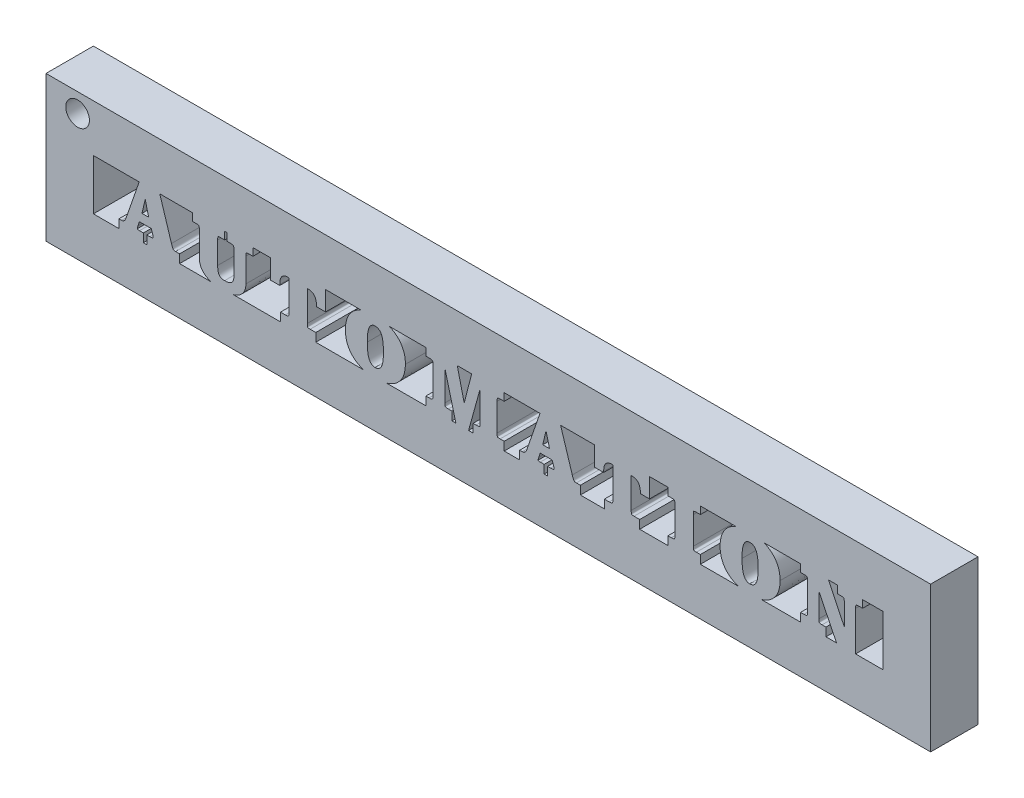
from build123d import *

# Parameters (mm, degrees)
BOSS_EXTRUDE1_DEPTH    = 3
BOSS_EXTRUDE1_2_DEPTH  = 3
BOSS_EXTRUDE1_3_DEPTH  = 3
BOSS_EXTRUDE1_4_DEPTH  = 3
BOSS_EXTRUDE1_5_DEPTH  = 3
BOSS_EXTRUDE1_6_DEPTH  = 3
BOSS_EXTRUDE1_7_DEPTH  = 3
BOSS_EXTRUDE1_8_DEPTH  = 3
BOSS_EXTRUDE1_9_DEPTH  = 3
BOSS_EXTRUDE1_10_DEPTH = 3
SKETCH3_W              = 56
SKETCH3_H              = 9.2
SKETCH3_W_2            = 50
SKETCH3_H_2            = 3.2
BOSS_EXTRUDE2_DEPTH    = 3
SKETCH4_R              = 0.75
CUT_EXTRUDE1_DEPTH     = 3


with BuildPart() as part:
    # Sketch2 → Boss-Extrude1 (new body)
    with BuildSketch(Plane.XY):
        with BuildLine():
            Line((3.381832038, 0), (3.381832038, 0.536056858))
            Line((3.381832038, 0.536056858), (3.570987518, 0.536056858))
            add(Edge.make_bspline(
                [(3.570987518, 0.536056858), (3.596342853, 0.536171578), (3.641017257, 0.536373708), (3.698829642, 0.53805499), (3.738173785, 0.541308891), (3.766455813, 0.545460082), (3.786381886, 0.562207471), (3.787958851, 0.579113011), (3.788760616, 0.587708169)],
                knots=[0, 0, 0, 0, 7.6084e-05, 0.000134055, 0.000173298, 0.0001948, 0.00021903, 0.00024409, 0.00024409, 0.00024409, 0.00024409], degree=3))
            add(Edge.make_bspline(
                [(3.788760616, 0.587708169), (3.788482764, 0.597959418), (3.787912273, 0.619007516), (3.783446166, 0.650694941), (3.77732226, 0.681848648), (3.772315457, 0.702195094), (3.769914867, 0.711950514)],
                knots=[0, 0, 0, 0, 3.0743e-05, 6.3123e-05, 9.5839e-05, 0.000125974, 0.000125974, 0.000125974, 0.000125974], degree=3))
            Line((3.769914867, 0.711950514), (3.665914253, 1.02744231))
            Line((3.665914253, 1.02744231), (2.912084297, 1.02744231))
            Line((2.912084297, 1.02744231), (2.821345506, 0.749642012))
            add(Edge.make_bspline(
                [(2.821345506, 0.749642012), (2.814741406, 0.729429284), (2.803333299, 0.694513256), (2.789391024, 0.648275702), (2.782829669, 0.611879239), (2.782916307, 0.590518691), (2.782956017, 0.580728262)],
                knots=[0, 0, 0, 0, 6.3793e-05, 0.000110197, 0.000144852, 0.000174176, 0.000174176, 0.000174176, 0.000174176], degree=3))
            add(Edge.make_bspline(
                [(2.782956017, 0.580728262), (2.784157263, 0.573240487), (2.786647185, 0.557719942), (2.805768298, 0.545459648), (2.826429588, 0.540840547), (2.850174249, 0.538549009), (2.881090993, 0.536254741), (2.904164107, 0.536127487), (2.916970232, 0.536056858)],
                knots=[0, 0, 0, 0, 2.1862e-05, 4.5315e-05, 6.1906e-05, 8.5801e-05, 0.000116584, 0.00015498, 0.00015498, 0.00015498, 0.00015498], degree=3))
            Line((2.916970232, 0.536056858), (3.16475693, 0.536056858))
            Line((3.16475693, 0.536056858), (3.16475693, 0))
            Line((3.16475693, 0), (1.614519586, 0))
            Line((1.614519586, 0), (1.614519586, 0.536056858))
            Line((1.614519586, 0.536056858), (1.777151419, 0.536056858))
            add(Edge.make_bspline(
                [(1.777151419, 0.536056858), (1.793748064, 0.536834102), (1.826279255, 0.538357585), (1.872910412, 0.551114453), (1.915175634, 0.572783209), (1.954099296, 0.603015499), (1.989492009, 0.644535735), (2.022918471, 0.697314513), (2.053043362, 0.762945126), (2.070671551, 0.811159662), (2.080079382, 0.836890849)],
                knots=[0, 0, 0, 0, 4.9734e-05, 9.7484e-05, 0.000143683, 0.000191433, 0.000244356, 0.000306509, 0.000378321, 0.000460506, 0.000460506, 0.000460506, 0.000460506], degree=3))
            Line((2.080079382, 0.836890849), (2.919762195, 3.261012551))
            Line((2.919762195, 3.261012551), (4.183823352, 3.261012551))
            Line((4.183823352, 3.261012551), (4.941841253, 0.845266738))
            add(Edge.make_bspline(
                [(4.941841253, 0.845266738), (4.948028917, 0.826155434), (4.959679339, 0.790171785), (4.977625901, 0.739629309), (4.992775532, 0.69487605), (5.009294359, 0.657628397), (5.023108468, 0.626144229), (5.036090496, 0.601384535), (5.047744758, 0.582505931), (5.062855526, 0.566034588), (5.086036632, 0.553350471), (5.117765077, 0.5431571), (5.156363257, 0.536965551), (5.184253211, 0.53637667), (5.199399821, 0.536056858)],
                knots=[0, 0, 0, 0, 6.0258e-05, 0.000113457, 0.000160925, 0.000201893, 0.000235629, 0.000264041, 0.000285724, 0.000302019, 0.000330508, 0.000363617, 0.000401828, 0.000447246, 0.000447246, 0.000447246, 0.000447246], degree=3))
            Line((5.199399821, 0.536056858), (5.456260399, 0.536056858))
            Line((5.456260399, 0.536056858), (5.456260399, 0))
            Line((5.456260399, 0), (3.381832038, 0))
        make_face()
        Polygon((3.502584429, 1.563499168), (3.279925396, 2.434591562), (3.074018139, 1.563499168), align=None, mode=Mode.SUBTRACT)
    extrude(amount=BOSS_EXTRUDE1_DEPTH)



with BuildPart() as body_2:
    # Sketch2 → Boss-Extrude1 2 (new body)
    with BuildSketch(Plane.XY):
        with BuildLine():
            add(Edge.make_bspline(
                [(7.868516258, 1.10701325), (7.868707123, 1.077923127), (7.869072362, 1.022256245), (7.873932025, 0.942342272), (7.882204374, 0.869888516), (7.893278232, 0.804852562), (7.906709904, 0.7469007), (7.924849947, 0.696675514), (7.945830395, 0.653570995), (7.969517199, 0.616709057), (7.998666652, 0.587190467), (8.030082332, 0.560826844), (8.066150595, 0.539101064), (8.106422363, 0.521805027), (8.150550321, 0.507704864), (8.198785943, 0.498175384), (8.250886173, 0.492655301), (8.286831413, 0.491818887), (8.305458436, 0.491385453)],
                knots=[0, 0, 0, 0, 8.726e-05, 0.000166981, 0.000240053, 0.00030592, 0.000364833, 0.000418265, 0.000465713, 0.000508496, 0.000548979, 0.000589643, 0.000631301, 0.000674745, 0.000720881, 0.000770023, 0.000821976, 0.000877854, 0.000877854, 0.000877854, 0.000877854], degree=3))
            add(Edge.make_bspline(
                [(8.305458436, 0.491385453), (8.331303094, 0.491722183), (8.380980465, 0.492369429), (8.452473231, 0.499092046), (8.518487406, 0.508064313), (8.578500462, 0.523234703), (8.633484757, 0.540558083), (8.681798096, 0.564178469), (8.725003671, 0.590312162), (8.762000991, 0.621800119), (8.794233967, 0.658067778), (8.820898537, 0.700462835), (8.84537275, 0.747484067), (8.863643675, 0.80100877), (8.878312449, 0.85985571), (8.888541078, 0.92431251), (8.894874761, 0.994276445), (8.895588581, 1.042783561), (8.895958568, 1.067925771)],
                knots=[0, 0, 0, 0, 7.7505e-05, 0.000148977, 0.000215312, 0.000277103, 0.000334491, 0.000387877, 0.00043804, 0.000485585, 0.000533059, 0.000583008, 0.00063545, 0.000691746, 0.000752182, 0.000817245, 0.000887326, 0.000962738, 0.000962738, 0.000962738, 0.000962738], degree=3))
            Line((8.895958568, 1.067925771), (8.895958568, 2.500202688))
            add(Edge.make_bspline(
                [(8.895958568, 2.500202688), (8.895768763, 2.524886933), (8.895431099, 2.568800309), (8.888621896, 2.626444708), (8.87934257, 2.667875118), (8.862185167, 2.697373844), (8.830958932, 2.71101168), (8.789394628, 2.718684183), (8.732490529, 2.723987746), (8.689589849, 2.724608746), (8.665621637, 2.724955693)],
                knots=[0, 0, 0, 0, 7.4017e-05, 0.000131676, 0.000173672, 0.000201355, 0.000229767, 0.000271936, 0.000328749, 0.000400672, 0.000400672, 0.000400672, 0.000400672], degree=3))
            Line((8.665621637, 2.724955693), (8.44924452, 2.724955693))
            Line((8.44924452, 2.724955693), (8.44924452, 3.261012551))
            Line((8.44924452, 3.261012551), (10.102086498, 3.261012551))
            Line((10.102086498, 3.261012551), (10.102086498, 2.724955693))
            Line((10.102086498, 2.724955693), (9.852903818, 2.724955693))
            add(Edge.make_bspline(
                [(9.852903818, 2.724955693), (9.83197497, 2.724824859), (9.794690979, 2.724591782), (9.745368172, 2.720083001), (9.710238708, 2.712923942), (9.682722037, 2.702892056), (9.668710345, 2.675488816), (9.66165712, 2.636803368), (9.656236887, 2.581033839), (9.655685291, 2.538363339), (9.65537245, 2.514162502)],
                knots=[0, 0, 0, 0, 6.2835e-05, 0.000111938, 0.000147672, 0.000171709, 0.000195533, 0.000234981, 0.000290404, 0.000363025, 0.000363025, 0.000363025, 0.000363025], degree=3))
            Line((9.65537245, 2.514162502), (9.65537245, 0.989750813))
            add(Edge.make_bspline(
                [(9.65537245, 0.989750813), (9.654175093, 0.947803989), (9.651841742, 0.866060123), (9.633399012, 0.747046894), (9.602876321, 0.635393575), (9.559408101, 0.531107207), (9.50281535, 0.434775672), (9.43459066, 0.345263785), (9.353728717, 0.263454323), (9.261063587, 0.189097827), (9.156378237, 0.123577708), (9.040370538, 0.066225613), (8.913318827, 0.017439247), (8.774610058, -0.02131287), (8.62505696, -0.051746424), (8.463986775, -0.073943293), (8.291724772, -0.087241597), (8.173097138, -0.088629394), (8.112115012, -0.08934281)],
                knots=[0, 0, 0, 0, 0.000125795, 0.000245144, 0.000360295, 0.000472296, 0.00058303, 0.000694574, 0.000809082, 0.000927247, 0.001050214, 0.001178821, 0.001314927, 0.001457879, 0.001610374, 0.001772458, 0.001945371, 0.002128292, 0.002128292, 0.002128292, 0.002128292], degree=3))
            add(Edge.make_bspline(
                [(8.112115012, -0.08934281), (8.058348019, -0.088558927), (7.953684375, -0.08703301), (7.801139761, -0.074638252), (7.657867159, -0.052738044), (7.523199971, -0.024141065), (7.39823319, 0.014484406), (7.281852305, 0.060439148), (7.174904107, 0.115495291), (7.077566607, 0.179078755), (6.990269738, 0.250288656), (6.914854002, 0.329676728), (6.849351673, 0.415095977), (6.797797101, 0.509106111), (6.757021701, 0.609607696), (6.727734585, 0.717106499), (6.709908252, 0.831640403), (6.708024614, 0.910346597), (6.707059733, 0.950663333)],
                knots=[0, 0, 0, 0, 0.00016129, 0.00031397, 0.000458685, 0.000595868, 0.000726573, 0.000850613, 0.000970802, 0.001086765, 0.001198835, 0.001307939, 0.001414592, 0.001520826, 0.001628537, 0.00173928, 0.001854383, 0.001975264, 0.001975264, 0.001975264, 0.001975264], degree=3))
            Line((6.707059733, 0.950663333), (6.707059733, 2.500202688))
            add(Edge.make_bspline(
                [(6.707059733, 2.500202688), (6.706814492, 2.52417641), (6.706377371, 2.566907454), (6.700086066, 2.623358829), (6.689284834, 2.664306778), (6.672002427, 2.694433509), (6.640294362, 2.709932178), (6.597913611, 2.717876999), (6.540866583, 2.724270361), (6.497914307, 2.724710134), (6.473930839, 2.724955693)],
                knots=[0, 0, 0, 0, 7.1924e-05, 0.000128197, 0.000169715, 0.000198947, 0.000228642, 0.000271647, 0.000328532, 0.000400455, 0.000400455, 0.000400455, 0.000400455], degree=3))
            Line((6.473930839, 2.724955693), (6.260345685, 2.724955693))
            Line((6.260345685, 2.724955693), (6.260345685, 3.261012551))
            Line((6.260345685, 3.261012551), (8.315230306, 3.261012551))
            Line((8.315230306, 3.261012551), (8.315230306, 2.724955693))
            Line((8.315230306, 2.724955693), (8.047899868, 2.724955693))
            add(Edge.make_bspline(
                [(8.047899868, 2.724955693), (8.029048445, 2.724842914), (7.995217807, 2.724640523), (7.950455591, 2.719858127), (7.917814983, 2.713337696), (7.892497853, 2.701349448), (7.879886533, 2.672944288), (7.874601773, 2.631738955), (7.868338274, 2.572216321), (7.868451821, 2.526274171), (7.868516258, 2.500202688)],
                knots=[0, 0, 0, 0, 5.6554e-05, 0.000101492, 0.000134505, 0.000157015, 0.000181692, 0.000222897, 0.000282489, 0.000360676, 0.000360676, 0.000360676, 0.000360676], degree=3))
            Line((7.868516258, 2.500202688), (7.868516258, 1.10701325))
        make_face()
    extrude(amount=BOSS_EXTRUDE1_2_DEPTH)


with BuildPart() as body_3:
    # Sketch2 → Boss-Extrude1 3 (new body)
    with BuildSketch(Plane.XY):
        with BuildLine():
            add(Edge.make_bspline(
                [(12.279119492, 2.680284288), (12.261188832, 2.679636513), (12.226123323, 2.678369713), (12.174737753, 2.671723374), (12.126699318, 2.658843822), (12.081036093, 2.642148757), (12.038503664, 2.619606552), (11.998708109, 2.592419951), (11.961763568, 2.560300878), (11.927604834, 2.523659756), (11.897408311, 2.481052415), (11.870754161, 2.43341156), (11.848511744, 2.379968596), (11.830471135, 2.321041416), (11.816582842, 2.256582581), (11.807235729, 2.186551757), (11.800636235, 2.111080948), (11.799953109, 2.058855491), (11.799599881, 2.031850928)],
                knots=[0, 0, 0, 0, 5.3818e-05, 0.000105247, 0.00015502, 0.000202729, 0.00025081, 0.000299016, 0.000347016, 0.000397397, 0.000448921, 0.000503292, 0.00056085, 0.000622226, 0.000687941, 0.00075842, 0.000834065, 0.000915059, 0.000915059, 0.000915059, 0.000915059], degree=3))
            Line((11.799599881, 2.031850928), (11.799599881, 1.9739177))
            Line((11.799599881, 1.9739177), (11.218871618, 1.9739177))
            Line((11.218871618, 1.9739177), (11.218871618, 3.261012551))
            Line((11.218871618, 3.261012551), (14.703241193, 3.261012551))
            Line((14.703241193, 3.261012551), (14.703241193, 1.9739177))
            Line((14.703241193, 1.9739177), (14.12251293, 1.9739177))
            Line((14.12251293, 1.9739177), (14.12251293, 2.031850928))
            add(Edge.make_bspline(
                [(14.12251293, 2.031850928), (14.122109942, 2.05768537), (14.121328107, 2.107806652), (14.115338178, 2.180656207), (14.103747074, 2.248365992), (14.089814371, 2.311706246), (14.069595289, 2.369734423), (14.047347907, 2.423862222), (14.018964656, 2.472347558), (13.986755068, 2.515752782), (13.950967077, 2.554675432), (13.910837575, 2.588404091), (13.866957755, 2.616911762), (13.819203251, 2.640445536), (13.767851178, 2.658362023), (13.712577821, 2.670863551), (13.653684814, 2.678661352), (13.613004958, 2.679732339), (13.592039998, 2.680284288)],
                knots=[0, 0, 0, 0, 7.7505e-05, 0.000150368, 0.000218988, 0.000283494, 0.000344635, 0.000403108, 0.000458777, 0.000512663, 0.000565017, 0.00061703, 0.000669495, 0.000721625, 0.000776372, 0.000832246, 0.000891378, 0.000954259, 0.000954259, 0.000954259, 0.000954259], degree=3))
            Line((13.592039998, 2.680284288), (13.541784668, 2.680284288))
            Line((13.541784668, 2.680284288), (13.541784668, 0.764997807))
            add(Edge.make_bspline(
                [(13.541784668, 0.764997807), (13.541765258, 0.738478477), (13.541731145, 0.691870055), (13.547550118, 0.630977659), (13.55401725, 0.589225928), (13.566237487, 0.559444145), (13.592204092, 0.548029508), (13.624346101, 0.54101405), (13.668509319, 0.536415579), (13.701860283, 0.536185335), (13.720470287, 0.536056858)],
                knots=[0, 0, 0, 0, 7.9583e-05, 0.00013987, 0.000182578, 0.00020787, 0.000230988, 0.000263323, 0.000307567, 0.000363424, 0.000363424, 0.000363424, 0.000363424], degree=3))
            Line((13.720470287, 0.536056858), (14.077841526, 0.536056858))
            Line((14.077841526, 0.536056858), (14.077841526, 0))
            Line((14.077841526, 0), (11.844271285, 0))
            Line((11.844271285, 0), (11.844271285, 0.536056858))
            Line((11.844271285, 0.536056858), (12.149991212, 0.536056858))
            add(Edge.make_bspline(
                [(12.149991212, 0.536056858), (12.173261577, 0.536087275), (12.215005856, 0.536141841), (12.270706264, 0.541822249), (12.311677494, 0.549129584), (12.343908431, 0.560765498), (12.362705215, 0.590208826), (12.372353433, 0.63291486), (12.380106865, 0.692854114), (12.380248114, 0.738905894), (12.380328143, 0.764997807)],
                knots=[0, 0, 0, 0, 6.9813e-05, 0.000125236, 0.000167261, 0.000195682, 0.000224163, 0.00026702, 0.000326844, 0.000405047, 0.000405047, 0.000405047, 0.000405047], degree=3))
            Line((12.380328143, 0.764997807), (12.380328143, 2.680284288))
            Line((12.380328143, 2.680284288), (12.279119492, 2.680284288))
        make_face()
    extrude(amount=BOSS_EXTRUDE1_3_DEPTH)


with BuildPart() as body_4:
    # Sketch2 → Boss-Extrude1 4 (new body)
    with BuildSketch(Plane.XY):
        with BuildLine():
            add(Edge.make_bspline(
                [(15.954040527, 1.628412303), (15.955360908, 1.693871405), (15.957935735, 1.821520791), (15.982420667, 2.007230092), (16.02086911, 2.182340646), (16.076650373, 2.34627067), (16.145988685, 2.500575332), (16.233399644, 2.642867483), (16.33610488, 2.774304619), (16.453544173, 2.894467164), (16.584777963, 3.002061051), (16.728852005, 3.095042276), (16.88426974, 3.174540771), (17.051558104, 3.239241172), (17.23059163, 3.289630125), (17.4212787, 3.324537203), (17.623569439, 3.346831303), (17.762473223, 3.349160504), (17.833729483, 3.35035536)],
                knots=[0, 0, 0, 0, 0.000196286, 0.000382769, 0.00056091, 0.000733297, 0.000901339, 0.001067374, 0.001232969, 0.001400789, 0.001570416, 0.00174098, 0.001914231, 0.002093235, 0.002278182, 0.002471344, 0.00267422, 0.002887919, 0.002887919, 0.002887919, 0.002887919], degree=3))
            add(Edge.make_bspline(
                [(17.833729483, 3.35035536), (17.906850767, 3.349221369), (18.049499578, 3.347009121), (18.257120018, 3.323849865), (18.452680847, 3.288293271), (18.635735264, 3.237385548), (18.80649817, 3.17165401), (18.964827217, 3.091168279), (19.111528855, 2.996520673), (19.244354727, 2.886735701), (19.364169864, 2.765490921), (19.46795862, 2.632813836), (19.555853872, 2.490271065), (19.627329958, 2.337474619), (19.683476559, 2.174681532), (19.722798252, 2.001507145), (19.74715365, 1.818263654), (19.749770133, 1.692705801), (19.751109936, 1.628412303)],
                knots=[0, 0, 0, 0, 0.00021928, 0.000427783, 0.000625876, 0.000815043, 0.000996903, 0.001173897, 0.001346978, 0.001519552, 0.001689835, 0.001857389, 0.002023789, 0.002191151, 0.002362442, 0.002539377, 0.002723092, 0.00291589, 0.00291589, 0.00291589, 0.00291589], degree=3))
            add(Edge.make_bspline(
                [(19.751109936, 1.628412303), (19.74982705, 1.564113301), (19.747316508, 1.438283469), (19.722117912, 1.255085513), (19.682463731, 1.082100979), (19.627532121, 0.918854457), (19.55511083, 0.766220375), (19.467515305, 0.623361067), (19.363377355, 0.491384274), (19.24388928, 0.370692375), (19.110250138, 0.262333814), (18.963614508, 0.167624398), (18.804163232, 0.08780829), (18.632078817, 0.023077635), (18.44800686, -0.027873049), (18.251353239, -0.063822887), (18.042232405, -0.085760031), (17.898465443, -0.088127403), (17.824655603, -0.08934281)],
                knots=[0, 0, 0, 0, 0.000192798, 0.000377296, 0.000553551, 0.000724616, 0.000892907, 0.001059307, 0.001226312, 0.001396098, 0.001567789, 0.001741456, 0.001918758, 0.002101671, 0.002292183, 0.002490962, 0.00270078, 0.002922153, 0.002922153, 0.002922153, 0.002922153], degree=3))
            add(Edge.make_bspline(
                [(17.824655603, -0.08934281), (17.753863411, -0.088152744), (17.615885397, -0.085833238), (17.41476986, -0.063456884), (17.224989043, -0.028653218), (17.046987691, 0.021791519), (16.880302739, 0.085958279), (16.725494244, 0.165116317), (16.581940534, 0.258246674), (16.451432124, 0.366093247), (16.333985429, 0.48578982), (16.231940759, 0.617471422), (16.145620817, 0.759800337), (16.075706703, 0.913155321), (16.020989193, 1.076935386), (15.982440012, 1.251445896), (15.957967733, 1.436469133), (15.955370291, 1.563419766), (15.954040527, 1.628412303)],
                knots=[0, 0, 0, 0, 0.000212304, 0.000413792, 0.000606268, 0.000790543, 0.000967994, 0.001141244, 0.001311223, 0.001480312, 0.001648131, 0.001813297, 0.00197897, 0.002146377, 0.00231788, 0.002496021, 0.002681812, 0.002876703, 0.002876703, 0.002876703, 0.002876703], degree=3))
        make_face()
        with BuildLine():
            add(Edge.make_bspline(
                [(17.832333501, 2.769627098), (17.813201703, 2.768771897), (17.77549381, 2.767086336), (17.720644286, 2.755272428), (17.669572131, 2.734337274), (17.621519099, 2.706317637), (17.57713646, 2.669402601), (17.5367835, 2.623996383), (17.498873249, 2.571638984), (17.465156293, 2.510415797), (17.434908336, 2.439935077), (17.409551054, 2.358180351), (17.387440313, 2.26561374), (17.369465261, 2.16163292), (17.355747999, 2.046530871), (17.346441968, 1.920059115), (17.33987621, 1.782503939), (17.339203434, 1.6870521), (17.338854076, 1.637486182)],
                knots=[0, 0, 0, 0, 5.7388e-05, 0.00011311, 0.000167288, 0.000222354, 0.000279372, 0.000339658, 0.000404165, 0.000472909, 0.000548888, 0.000633874, 0.000729356, 0.00083424, 0.000950252, 0.001076965, 0.001214613, 0.0013633, 0.0013633, 0.0013633, 0.0013633], degree=3))
            add(Edge.make_bspline(
                [(17.338854076, 1.637486182), (17.33931872, 1.58699535), (17.340214049, 1.489703957), (17.345251336, 1.349507706), (17.355913502, 1.221022831), (17.369694323, 1.104117508), (17.386647005, 0.99867508), (17.40802561, 0.90484333), (17.433561791, 0.822502784), (17.463739001, 0.751298562), (17.497391339, 0.68973311), (17.534468059, 0.637111288), (17.574557463, 0.592012324), (17.618848482, 0.555755347), (17.665976781, 0.526337438), (17.716998921, 0.5059455), (17.771507454, 0.493831607), (17.809005074, 0.492212115), (17.828145557, 0.491385453)],
                knots=[0, 0, 0, 0, 0.000151478, 0.000291886, 0.000420742, 0.000538139, 0.000644971, 0.000740972, 0.000826623, 0.000903243, 0.000972598, 0.001036699, 0.001095999, 0.001153017, 0.001207844, 0.001262022, 0.001317062, 0.00137445, 0.00137445, 0.00137445, 0.00137445], degree=3))
            add(Edge.make_bspline(
                [(17.828145557, 0.491385453), (17.850524295, 0.492236693), (17.894212513, 0.493898501), (17.957710725, 0.505496917), (18.016250415, 0.527037919), (18.070460535, 0.555674981), (18.120040225, 0.592463144), (18.164382459, 0.637777298), (18.203528975, 0.691649366), (18.238697319, 0.753891209), (18.269508466, 0.825671097), (18.294696292, 0.908009918), (18.317034682, 1.000778373), (18.335720016, 1.104213428), (18.349414728, 1.218901686), (18.358687483, 1.344210164), (18.365268062, 1.480369437), (18.365945358, 1.574658426), (18.366296387, 1.623526368)],
                knots=[0, 0, 0, 0, 6.7138e-05, 0.000131068, 0.000192669, 0.000253559, 0.000314424, 0.000377107, 0.000443, 0.000513646, 0.000591182, 0.000676833, 0.000771637, 0.000877331, 0.000991957, 0.001117975, 0.001254228, 0.001400821, 0.001400821, 0.001400821, 0.001400821], degree=3))
            add(Edge.make_bspline(
                [(18.366296387, 1.623526368), (18.365955974, 1.672860661), (18.365300539, 1.767849392), (18.358608273, 1.904925509), (18.349634769, 2.031464901), (18.334772963, 2.146918514), (18.317034217, 2.251647222), (18.294840722, 2.345433045), (18.268816217, 2.428753976), (18.237802287, 2.501627693), (18.203097517, 2.565085668), (18.163461619, 2.619531393), (18.120120262, 2.666320661), (18.071600634, 2.704716665), (18.017633275, 2.733273922), (17.959953188, 2.754504241), (17.897579744, 2.767417644), (17.854498846, 2.768876506), (17.832333501, 2.769627098)],
                knots=[0, 0, 0, 0, 0.000147989, 0.000284939, 0.000411653, 0.000528443, 0.000634015, 0.000730176, 0.000817369, 0.000895547, 0.000967409, 0.001033865, 0.001097071, 0.001158228, 0.001218502, 0.001279447, 0.001342142, 0.001408584, 0.001408584, 0.001408584, 0.001408584], degree=3))
        make_face(mode=Mode.SUBTRACT)
    extrude(amount=BOSS_EXTRUDE1_4_DEPTH)


with BuildPart() as body_5:
    # Sketch2 → Boss-Extrude1 5 (new body)
    with BuildSketch(Plane.XY):
        with BuildLine():
            Line((26.005106608, 3.261012551), (26.005106608, 2.724955693))
            Line((26.005106608, 2.724955693), (25.746850049, 2.724955693))
            add(Edge.make_bspline(
                [(25.746850049, 2.724955693), (25.726854722, 2.724771649), (25.691455029, 2.724445819), (25.644259348, 2.720499589), (25.610759162, 2.714416491), (25.583711592, 2.704667841), (25.571285474, 2.675978268), (25.563437978, 2.634892014), (25.559713022, 2.573226067), (25.558870856, 2.525762795), (25.55839256, 2.498806706)],
                knots=[0, 0, 0, 0, 6.0043e-05, 0.000106301, 0.000141207, 0.000163684, 0.000187752, 0.00022924, 0.000290857, 0.000371851, 0.000371851, 0.000371851, 0.000371851], degree=3))
            Line((25.55839256, 2.498806706), (25.55839256, 0.764299817))
            add(Edge.make_bspline(
                [(25.55839256, 0.764299817), (25.558879602, 0.737118933), (25.559738152, 0.689204955), (25.563390473, 0.626769039), (25.571439238, 0.585191845), (25.58352759, 0.555460865), (25.611063421, 0.546084738), (25.644766271, 0.540634096), (25.691688502, 0.536551091), (25.727087178, 0.536233928), (25.746850049, 0.536056858)],
                knots=[0, 0, 0, 0, 8.1692e-05, 0.000144005, 0.000186174, 0.000210852, 0.000233959, 0.000268047, 0.000314999, 0.000374345, 0.000374345, 0.000374345, 0.000374345], degree=3))
            Line((25.746850049, 0.536056858), (26.005106608, 0.536056858))
            Line((26.005106608, 0.536056858), (26.005106608, 0))
            Line((26.005106608, 0), (24.039564797, 0))
            Line((24.039564797, 0), (24.039564797, 0.536056858))
            Line((24.039564797, 0.536056858), (24.223136351, 0.536056858))
            add(Edge.make_bspline(
                [(24.223136351, 0.536056858), (24.249405439, 0.536564937), (24.296652605, 0.537478761), (24.360043958, 0.541161067), (24.406422793, 0.550219335), (24.442876601, 0.560756755), (24.465539997, 0.590105625), (24.477396779, 0.633384207), (24.485236333, 0.693054279), (24.485903824, 0.738670767), (24.486278845, 0.764299817)],
                knots=[0, 0, 0, 0, 7.8901e-05, 0.00014191, 0.000189547, 0.000221821, 0.000252029, 0.000295512, 0.00035543, 0.000432259, 0.000432259, 0.000432259, 0.000432259], degree=3))
            Line((24.486278845, 0.764299817), (24.486278845, 2.653062651))
            Line((24.486278845, 2.653062651), (23.750596647, 0))
            Line((23.750596647, 0), (22.945115379, 0))
            Line((22.945115379, 0), (22.252708605, 2.648874707))
            Line((22.252708605, 2.648874707), (22.252708605, 0.764299817))
            add(Edge.make_bspline(
                [(22.252708605, 0.764299817), (22.252953986, 0.738003356), (22.253389232, 0.691360075), (22.259520042, 0.630677839), (22.267245667, 0.588420414), (22.282567303, 0.558625395), (22.31310647, 0.547774477), (22.352065791, 0.541106855), (22.406687489, 0.536340106), (22.447922671, 0.536159002), (22.471179694, 0.536056858)],
                knots=[0, 0, 0, 0, 7.8901e-05, 0.00013995, 0.000182275, 0.000208614, 0.000234842, 0.000274677, 0.000328644, 0.000398457, 0.000398457, 0.000398457, 0.000398457], degree=3))
            Line((22.471179694, 0.536056858), (22.699422653, 0.536056858))
            Line((22.699422653, 0.536056858), (22.699422653, 0))
            Line((22.699422653, 0), (21.046580675, 0))
            Line((21.046580675, 0), (21.046580675, 0.536056858))
            Line((21.046580675, 0.536056858), (21.25109195, 0.536056858))
            add(Edge.make_bspline(
                [(21.25109195, 0.536056858), (21.276210505, 0.536458177), (21.321178003, 0.537176624), (21.380812012, 0.541902872), (21.424255845, 0.550937555), (21.457476335, 0.564765695), (21.475952221, 0.59553647), (21.486114604, 0.637730373), (21.492696239, 0.695717703), (21.493079364, 0.739621151), (21.493294723, 0.764299817)],
                knots=[0, 0, 0, 0, 7.5412e-05, 0.000135003, 0.000178688, 0.00020928, 0.000238902, 0.000281759, 0.000339418, 0.000413434, 0.000413434, 0.000413434, 0.000413434], degree=3))
            Line((21.493294723, 0.764299817), (21.493294723, 2.498806706))
            add(Edge.make_bspline(
                [(21.493294723, 2.498806706), (21.493080131, 2.523482868), (21.492700378, 2.567150893), (21.48619412, 2.62471167), (21.475855197, 2.666047384), (21.458048524, 2.69620274), (21.425289284, 2.710377584), (21.381696095, 2.718938356), (21.321658558, 2.723911759), (21.276448566, 2.724580577), (21.25109195, 2.724955693)],
                knots=[0, 0, 0, 0, 7.4017e-05, 0.000130983, 0.00017317, 0.000201821, 0.000231794, 0.000276159, 0.000335751, 0.000411861, 0.000411861, 0.000411861, 0.000411861], degree=3))
            Line((21.25109195, 2.724955693), (21.046580675, 2.724955693))
            Line((21.046580675, 2.724955693), (21.046580675, 3.261012551))
            Line((21.046580675, 3.261012551), (23.019800384, 3.261012551))
            Line((23.019800384, 3.261012551), (23.472796348, 1.368759763))
            Line((23.472796348, 1.368759763), (23.962087829, 3.261012551))
            Line((23.962087829, 3.261012551), (26.005106608, 3.261012551))
        make_face()
    extrude(amount=BOSS_EXTRUDE1_5_DEPTH)


with BuildPart() as body_6:
    # Sketch2 → Boss-Extrude1 6 (new body)
    with BuildSketch(Plane.XY):
        with BuildLine():
            Line((28.755189966, 0), (28.755189966, 0.536056858))
            Line((28.755189966, 0.536056858), (28.944345446, 0.536056858))
            add(Edge.make_bspline(
                [(28.944345446, 0.536056858), (28.969700782, 0.536171578), (29.014375186, 0.536373708), (29.07218757, 0.53805499), (29.111531713, 0.541308891), (29.139813741, 0.545460082), (29.159739814, 0.562207471), (29.16131678, 0.579113011), (29.162118544, 0.587708169)],
                knots=[0, 0, 0, 0, 7.6084e-05, 0.000134055, 0.000173298, 0.0001948, 0.00021903, 0.00024409, 0.00024409, 0.00024409, 0.00024409], degree=3))
            add(Edge.make_bspline(
                [(29.162118544, 0.587708169), (29.161840693, 0.597959418), (29.161270201, 0.619007516), (29.156804094, 0.650694941), (29.150680188, 0.681848648), (29.145673385, 0.702195094), (29.143272796, 0.711950514)],
                knots=[0, 0, 0, 0, 3.0743e-05, 6.3123e-05, 9.5839e-05, 0.000125974, 0.000125974, 0.000125974, 0.000125974], degree=3))
            Line((29.143272796, 0.711950514), (29.039272181, 1.02744231))
            Line((29.039272181, 1.02744231), (28.285442225, 1.02744231))
            Line((28.285442225, 1.02744231), (28.194703434, 0.749642012))
            add(Edge.make_bspline(
                [(28.194703434, 0.749642012), (28.188099334, 0.729429284), (28.176691227, 0.694513256), (28.162748953, 0.648275702), (28.156187597, 0.611879239), (28.156274236, 0.590518691), (28.156313946, 0.580728262)],
                knots=[0, 0, 0, 0, 6.3793e-05, 0.000110197, 0.000144852, 0.000174176, 0.000174176, 0.000174176, 0.000174176], degree=3))
            add(Edge.make_bspline(
                [(28.156313946, 0.580728262), (28.157515191, 0.573240487), (28.160005113, 0.557719942), (28.179126226, 0.545459648), (28.199787517, 0.540840547), (28.223532177, 0.538549009), (28.254448921, 0.536254741), (28.277522035, 0.536127487), (28.29032816, 0.536056858)],
                knots=[0, 0, 0, 0, 2.1862e-05, 4.5315e-05, 6.1906e-05, 8.5801e-05, 0.000116584, 0.00015498, 0.00015498, 0.00015498, 0.00015498], degree=3))
            Line((28.29032816, 0.536056858), (28.538114859, 0.536056858))
            Line((28.538114859, 0.536056858), (28.538114859, 0))
            Line((28.538114859, 0), (26.987877514, 0))
            Line((26.987877514, 0), (26.987877514, 0.536056858))
            Line((26.987877514, 0.536056858), (27.150509347, 0.536056858))
            add(Edge.make_bspline(
                [(27.150509347, 0.536056858), (27.167105993, 0.536834102), (27.199637183, 0.538357585), (27.24626834, 0.551114453), (27.288533563, 0.572783209), (27.327457224, 0.603015499), (27.362849937, 0.644535735), (27.3962764, 0.697314513), (27.42640129, 0.762945126), (27.444029479, 0.811159662), (27.453437311, 0.836890849)],
                knots=[0, 0, 0, 0, 4.9734e-05, 9.7484e-05, 0.000143683, 0.000191433, 0.000244356, 0.000306509, 0.000378321, 0.000460506, 0.000460506, 0.000460506, 0.000460506], degree=3))
            Line((27.453437311, 0.836890849), (28.293120123, 3.261012551))
            Line((28.293120123, 3.261012551), (29.557181281, 3.261012551))
            Line((29.557181281, 3.261012551), (30.315199181, 0.845266738))
            add(Edge.make_bspline(
                [(30.315199181, 0.845266738), (30.321386845, 0.826155434), (30.333037267, 0.790171785), (30.350983829, 0.739629309), (30.36613346, 0.69487605), (30.382652287, 0.657628397), (30.396466396, 0.626144229), (30.409448424, 0.601384535), (30.421102686, 0.582505931), (30.436213454, 0.566034588), (30.45939456, 0.553350471), (30.491123006, 0.5431571), (30.529721185, 0.536965551), (30.557611139, 0.53637667), (30.572757749, 0.536056858)],
                knots=[0, 0, 0, 0, 6.0258e-05, 0.000113457, 0.000160925, 0.000201893, 0.000235629, 0.000264041, 0.000285724, 0.000302019, 0.000330508, 0.000363617, 0.000401828, 0.000447246, 0.000447246, 0.000447246, 0.000447246], degree=3))
            Line((30.572757749, 0.536056858), (30.829618327, 0.536056858))
            Line((30.829618327, 0.536056858), (30.829618327, 0))
            Line((30.829618327, 0), (28.755189966, 0))
        make_face()
        Polygon((28.875942357, 1.563499168), (28.653283324, 2.434591562), (28.447376068, 1.563499168), align=None, mode=Mode.SUBTRACT)
    extrude(amount=BOSS_EXTRUDE1_6_DEPTH)


with BuildPart() as body_7:
    # Sketch2 → Boss-Extrude1 7 (new body)
    with BuildSketch(Plane.XY):
        with BuildLine():
            add(Edge.make_bspline(
                [(32.783294296, 2.680284288), (32.765363636, 2.679636513), (32.730298128, 2.678369713), (32.678912558, 2.671723374), (32.630874123, 2.658843822), (32.585210898, 2.642148757), (32.542678469, 2.619606552), (32.502882913, 2.592419951), (32.465938373, 2.560300878), (32.431779639, 2.523659756), (32.401583116, 2.481052415), (32.374928966, 2.43341156), (32.352686549, 2.379968596), (32.334645939, 2.321041416), (32.320757647, 2.256582581), (32.311410534, 2.186551757), (32.30481104, 2.111080948), (32.304127914, 2.058855491), (32.303774685, 2.031850928)],
                knots=[0, 0, 0, 0, 5.3818e-05, 0.000105247, 0.00015502, 0.000202729, 0.00025081, 0.000299016, 0.000347016, 0.000397397, 0.000448921, 0.000503292, 0.00056085, 0.000622226, 0.000687941, 0.00075842, 0.000834065, 0.000915059, 0.000915059, 0.000915059, 0.000915059], degree=3))
            Line((32.303774685, 2.031850928), (32.303774685, 1.9739177))
            Line((32.303774685, 1.9739177), (31.723046423, 1.9739177))
            Line((31.723046423, 1.9739177), (31.723046423, 3.261012551))
            Line((31.723046423, 3.261012551), (35.207415998, 3.261012551))
            Line((35.207415998, 3.261012551), (35.207415998, 1.9739177))
            Line((35.207415998, 1.9739177), (34.626687735, 1.9739177))
            Line((34.626687735, 1.9739177), (34.626687735, 2.031850928))
            add(Edge.make_bspline(
                [(34.626687735, 2.031850928), (34.626284747, 2.05768537), (34.625502912, 2.107806652), (34.619512983, 2.180656207), (34.607921878, 2.248365992), (34.593989176, 2.311706246), (34.573770094, 2.369734423), (34.551522712, 2.423862222), (34.523139461, 2.472347558), (34.490929873, 2.515752782), (34.455141882, 2.554675432), (34.415012379, 2.588404091), (34.371132559, 2.616911762), (34.323378056, 2.640445536), (34.272025983, 2.658362023), (34.216752626, 2.670863551), (34.157859618, 2.678661352), (34.117179763, 2.679732339), (34.096214803, 2.680284288)],
                knots=[0, 0, 0, 0, 7.7505e-05, 0.000150368, 0.000218988, 0.000283494, 0.000344635, 0.000403108, 0.000458777, 0.000512663, 0.000565017, 0.00061703, 0.000669495, 0.000721625, 0.000776372, 0.000832246, 0.000891378, 0.000954259, 0.000954259, 0.000954259, 0.000954259], degree=3))
            Line((34.096214803, 2.680284288), (34.045959473, 2.680284288))
            Line((34.045959473, 2.680284288), (34.045959473, 0.764997807))
            add(Edge.make_bspline(
                [(34.045959473, 0.764997807), (34.045940063, 0.738478477), (34.04590595, 0.691870055), (34.051724923, 0.630977659), (34.058192055, 0.589225928), (34.070412292, 0.559444145), (34.096378896, 0.548029508), (34.128520906, 0.54101405), (34.172684124, 0.536415579), (34.206035088, 0.536185335), (34.224645092, 0.536056858)],
                knots=[0, 0, 0, 0, 7.9583e-05, 0.00013987, 0.000182578, 0.00020787, 0.000230988, 0.000263323, 0.000307567, 0.000363424, 0.000363424, 0.000363424, 0.000363424], degree=3))
            Line((34.224645092, 0.536056858), (34.58201633, 0.536056858))
            Line((34.58201633, 0.536056858), (34.58201633, 0))
            Line((34.58201633, 0), (32.34844609, 0))
            Line((32.34844609, 0), (32.34844609, 0.536056858))
            Line((32.34844609, 0.536056858), (32.654166017, 0.536056858))
            add(Edge.make_bspline(
                [(32.654166017, 0.536056858), (32.677436382, 0.536087275), (32.719180661, 0.536141841), (32.774881069, 0.541822249), (32.815852298, 0.549129584), (32.848083236, 0.560765498), (32.86688002, 0.590208826), (32.876528238, 0.63291486), (32.88428167, 0.692854114), (32.884422919, 0.738905894), (32.884502948, 0.764997807)],
                knots=[0, 0, 0, 0, 6.9813e-05, 0.000125236, 0.000167261, 0.000195682, 0.000224163, 0.00026702, 0.000326844, 0.000405047, 0.000405047, 0.000405047, 0.000405047], degree=3))
            Line((32.884502948, 0.764997807), (32.884502948, 2.680284288))
            Line((32.884502948, 2.680284288), (32.783294296, 2.680284288))
        make_face()
    extrude(amount=BOSS_EXTRUDE1_7_DEPTH)


with BuildPart() as body_8:
    # Sketch2 → Boss-Extrude1 8 (new body)
    with BuildSketch(Plane.XY):
        with BuildLine():
            Line((38.423757143, 3.261012551), (38.423757143, 2.724955693))
            Line((38.423757143, 2.724955693), (38.169688529, 2.724955693))
            add(Edge.make_bspline(
                [(38.169688529, 2.724955693), (38.14946052, 2.724785457), (38.113111523, 2.72447955), (38.064860358, 2.720294131), (38.030328832, 2.712440186), (38.002982638, 2.701016854), (37.990050587, 2.671685247), (37.982227163, 2.630640266), (37.9783219, 2.570696269), (37.977506225, 2.524842096), (37.977043095, 2.498806706)],
                knots=[0, 0, 0, 0, 6.0741e-05, 0.00010915, 0.000144362, 0.000168094, 0.000193721, 0.000235208, 0.000294738, 0.000372941, 0.000372941, 0.000372941, 0.000372941], degree=3))
            Line((37.977043095, 2.498806706), (37.977043095, 0.764299817))
            add(Edge.make_bspline(
                [(37.977043095, 0.764299817), (37.977352941, 0.738017698), (37.977896803, 0.691885471), (37.983306589, 0.631372077), (37.990507663, 0.589787578), (38.003754144, 0.559727273), (38.031613925, 0.548793478), (38.065995532, 0.540704227), (38.113817749, 0.536538735), (38.14969656, 0.536229286), (38.169688529, 0.536056858)],
                knots=[0, 0, 0, 0, 7.8901e-05, 0.000138492, 0.000181343, 0.00020697, 0.00023132, 0.000266532, 0.000314246, 0.00037429, 0.00037429, 0.00037429, 0.00037429], degree=3))
            Line((38.169688529, 0.536056858), (38.423757143, 0.536056858))
            Line((38.423757143, 0.536056858), (38.423757143, 0))
            Line((38.423757143, 0), (36.368872522, 0))
            Line((36.368872522, 0), (36.368872522, 0.536056858))
            Line((36.368872522, 0.536056858), (36.580363705, 0.536056858))
            add(Edge.make_bspline(
                [(36.580363705, 0.536056858), (36.604339826, 0.536337598), (36.64751022, 0.536843088), (36.704637933, 0.542898295), (36.747075194, 0.551398356), (36.779257116, 0.566538987), (36.797236773, 0.597274339), (36.807738797, 0.639357569), (36.815189139, 0.696595671), (36.815444386, 0.740078185), (36.81558657, 0.764299817)],
                knots=[0, 0, 0, 0, 7.1924e-05, 0.000129502, 0.000171827, 0.000202132, 0.000232331, 0.000274518, 0.000332266, 0.000404887, 0.000404887, 0.000404887, 0.000404887], degree=3))
            Line((36.81558657, 0.764299817), (36.81558657, 2.498806706))
            add(Edge.make_bspline(
                [(36.81558657, 2.498806706), (36.815363979, 2.523015886), (36.814968902, 2.565984632), (36.808481147, 2.622864155), (36.797944521, 2.664084493), (36.780452753, 2.694693799), (36.748431025, 2.709581834), (36.705825968, 2.718186036), (36.648197045, 2.724144127), (36.604568966, 2.724666099), (36.580363705, 2.724955693)],
                knots=[0, 0, 0, 0, 7.2621e-05, 0.000128895, 0.000171082, 0.000200314, 0.000230618, 0.000272943, 0.000331216, 0.000403837, 0.000403837, 0.000403837, 0.000403837], degree=3))
            Line((36.580363705, 2.724955693), (36.368872522, 2.724955693))
            Line((36.368872522, 2.724955693), (36.368872522, 3.261012551))
            Line((36.368872522, 3.261012551), (38.423757143, 3.261012551))
        make_face()
    extrude(amount=BOSS_EXTRUDE1_8_DEPTH)


with BuildPart() as body_9:
    # Sketch2 → Boss-Extrude1 9 (new body)
    with BuildSketch(Plane.XY):
        with BuildLine():
            add(Edge.make_bspline(
                [(39.674556478, 1.628412303), (39.675876859, 1.693871405), (39.678451685, 1.821520791), (39.702936618, 2.007230092), (39.741385061, 2.182340646), (39.797166323, 2.34627067), (39.866504635, 2.500575332), (39.953915594, 2.642867483), (40.056620831, 2.774304619), (40.174060124, 2.894467164), (40.305293914, 3.002061051), (40.449367956, 3.095042276), (40.60478569, 3.174540771), (40.772074054, 3.239241172), (40.951107581, 3.289630125), (41.141794651, 3.324537203), (41.34408539, 3.346831303), (41.482989173, 3.349160504), (41.554245433, 3.35035536)],
                knots=[0, 0, 0, 0, 0.000196286, 0.000382769, 0.00056091, 0.000733297, 0.000901339, 0.001067374, 0.001232969, 0.001400789, 0.001570416, 0.00174098, 0.001914231, 0.002093235, 0.002278182, 0.002471344, 0.00267422, 0.002887919, 0.002887919, 0.002887919, 0.002887919], degree=3))
            add(Edge.make_bspline(
                [(41.554245433, 3.35035536), (41.627366717, 3.349221369), (41.770015529, 3.347009121), (41.977635969, 3.323849865), (42.173196797, 3.288293271), (42.356251215, 3.237385548), (42.52701412, 3.17165401), (42.685343168, 3.091168279), (42.832044806, 2.996520673), (42.964870677, 2.886735701), (43.084685815, 2.765490921), (43.188474571, 2.632813836), (43.276369823, 2.490271065), (43.347845909, 2.337474619), (43.40399251, 2.174681532), (43.443314203, 2.001507145), (43.467669601, 1.818263654), (43.470286083, 1.692705801), (43.471625886, 1.628412303)],
                knots=[0, 0, 0, 0, 0.00021928, 0.000427783, 0.000625876, 0.000815043, 0.000996903, 0.001173897, 0.001346978, 0.001519552, 0.001689835, 0.001857389, 0.002023789, 0.002191151, 0.002362442, 0.002539377, 0.002723092, 0.00291589, 0.00291589, 0.00291589, 0.00291589], degree=3))
            add(Edge.make_bspline(
                [(43.471625886, 1.628412303), (43.470343, 1.564113301), (43.467832459, 1.438283469), (43.442633862, 1.255085513), (43.402979681, 1.082100979), (43.348048071, 0.918854457), (43.27562678, 0.766220375), (43.188031255, 0.623361067), (43.083893305, 0.491384274), (42.964405231, 0.370692375), (42.830766089, 0.262333814), (42.684130459, 0.167624398), (42.524679183, 0.08780829), (42.352594768, 0.023077635), (42.16852281, -0.027873049), (41.97186919, -0.063822887), (41.762748355, -0.085760031), (41.618981394, -0.088127403), (41.545171554, -0.08934281)],
                knots=[0, 0, 0, 0, 0.000192798, 0.000377296, 0.000553551, 0.000724616, 0.000892907, 0.001059307, 0.001226312, 0.001396098, 0.001567789, 0.001741456, 0.001918758, 0.002101671, 0.002292183, 0.002490962, 0.00270078, 0.002922153, 0.002922153, 0.002922153, 0.002922153], degree=3))
            add(Edge.make_bspline(
                [(41.545171554, -0.08934281), (41.474379361, -0.088152744), (41.336401348, -0.085833238), (41.13528581, -0.063456884), (40.945504993, -0.028653218), (40.767503642, 0.021791519), (40.60081869, 0.085958279), (40.446010195, 0.165116317), (40.302456485, 0.258246674), (40.171948074, 0.366093247), (40.05450138, 0.48578982), (39.95245671, 0.617471422), (39.866136768, 0.759800337), (39.796222653, 0.913155321), (39.741505144, 1.076935386), (39.702955962, 1.251445896), (39.678483684, 1.436469133), (39.675886242, 1.563419766), (39.674556478, 1.628412303)],
                knots=[0, 0, 0, 0, 0.000212304, 0.000413792, 0.000606268, 0.000790543, 0.000967994, 0.001141244, 0.001311223, 0.001480312, 0.001648131, 0.001813297, 0.00197897, 0.002146377, 0.00231788, 0.002496021, 0.002681812, 0.002876703, 0.002876703, 0.002876703, 0.002876703], degree=3))
        make_face()
        with BuildLine():
            add(Edge.make_bspline(
                [(41.552849452, 2.769627098), (41.533717653, 2.768771897), (41.496009761, 2.767086336), (41.441160237, 2.755272428), (41.390088081, 2.734337274), (41.34203505, 2.706317637), (41.297652411, 2.669402601), (41.25729945, 2.623996383), (41.219389199, 2.571638984), (41.185672244, 2.510415797), (41.155424287, 2.439935077), (41.130067004, 2.358180351), (41.107956264, 2.26561374), (41.089981212, 2.16163292), (41.07626395, 2.046530871), (41.066957918, 1.920059115), (41.060392161, 1.782503939), (41.059719384, 1.6870521), (41.059370027, 1.637486182)],
                knots=[0, 0, 0, 0, 5.7388e-05, 0.00011311, 0.000167288, 0.000222354, 0.000279372, 0.000339658, 0.000404165, 0.000472909, 0.000548888, 0.000633874, 0.000729356, 0.00083424, 0.000950252, 0.001076965, 0.001214613, 0.0013633, 0.0013633, 0.0013633, 0.0013633], degree=3))
            add(Edge.make_bspline(
                [(41.059370027, 1.637486182), (41.059834671, 1.58699535), (41.060729999, 1.489703957), (41.065767286, 1.349507706), (41.076429453, 1.221022831), (41.090210274, 1.104117508), (41.107162955, 0.99867508), (41.128541561, 0.90484333), (41.154077741, 0.822502784), (41.184254952, 0.751298562), (41.21790729, 0.68973311), (41.254984009, 0.637111288), (41.295073414, 0.592012324), (41.339364433, 0.555755347), (41.386492731, 0.526337438), (41.437514871, 0.5059455), (41.492023405, 0.493831607), (41.529521024, 0.492212115), (41.548661508, 0.491385453)],
                knots=[0, 0, 0, 0, 0.000151478, 0.000291886, 0.000420742, 0.000538139, 0.000644971, 0.000740972, 0.000826623, 0.000903243, 0.000972598, 0.001036699, 0.001095999, 0.001153017, 0.001207844, 0.001262022, 0.001317062, 0.00137445, 0.00137445, 0.00137445, 0.00137445], degree=3))
            add(Edge.make_bspline(
                [(41.548661508, 0.491385453), (41.571040245, 0.492236693), (41.614728464, 0.493898501), (41.678226675, 0.505496917), (41.736766365, 0.527037919), (41.790976486, 0.555674981), (41.840556176, 0.592463144), (41.88489841, 0.637777298), (41.924044926, 0.691649366), (41.95921327, 0.753891209), (41.990024416, 0.825671097), (42.015212242, 0.908009918), (42.037550632, 1.000778373), (42.056235966, 1.104213428), (42.069930679, 1.218901686), (42.079203433, 1.344210164), (42.085784012, 1.480369437), (42.086461309, 1.574658426), (42.086812337, 1.623526368)],
                knots=[0, 0, 0, 0, 6.7138e-05, 0.000131068, 0.000192669, 0.000253559, 0.000314424, 0.000377107, 0.000443, 0.000513646, 0.000591182, 0.000676833, 0.000771637, 0.000877331, 0.000991957, 0.001117975, 0.001254228, 0.001400821, 0.001400821, 0.001400821, 0.001400821], degree=3))
            add(Edge.make_bspline(
                [(42.086812337, 1.623526368), (42.086471924, 1.672860661), (42.08581649, 1.767849392), (42.079124223, 1.904925509), (42.070150719, 2.031464901), (42.055288913, 2.146918514), (42.037550168, 2.251647222), (42.015356672, 2.345433045), (41.989332168, 2.428753976), (41.958318237, 2.501627693), (41.923613468, 2.565085668), (41.883977569, 2.619531393), (41.840636212, 2.666320661), (41.792116584, 2.704716665), (41.738149225, 2.733273922), (41.680469139, 2.754504241), (41.618095694, 2.767417644), (41.575014796, 2.768876506), (41.552849452, 2.769627098)],
                knots=[0, 0, 0, 0, 0.000147989, 0.000284939, 0.000411653, 0.000528443, 0.000634015, 0.000730176, 0.000817369, 0.000895547, 0.000967409, 0.001033865, 0.001097071, 0.001158228, 0.001218502, 0.001279447, 0.001342142, 0.001408584, 0.001408584, 0.001408584, 0.001408584], degree=3))
        make_face(mode=Mode.SUBTRACT)
    extrude(amount=BOSS_EXTRUDE1_9_DEPTH)


with BuildPart() as body_10:
    # Sketch2 → Boss-Extrude1 10 (new body)
    with BuildSketch(Plane.XY):
        with BuildLine():
            Line((46.512771366, 3.261012551), (47.536723723, 1.123765027))
            Line((47.536723723, 1.123765027), (47.536723723, 2.498806706))
            add(Edge.make_bspline(
                [(47.536723723, 2.498806706), (47.536554741, 2.524192744), (47.536256203, 2.56904186), (47.529363985, 2.627582485), (47.520278235, 2.669476464), (47.502367725, 2.698719466), (47.47168598, 2.711013284), (47.43262346, 2.719809979), (47.37923292, 2.723564457), (47.3391767, 2.724457868), (47.316856653, 2.724955693)],
                knots=[0, 0, 0, 0, 7.611e-05, 0.000134462, 0.000176458, 0.000204534, 0.000232627, 0.000272075, 0.000325347, 0.000392386, 0.000392386, 0.000392386, 0.000392386], degree=3))
            Line((47.316856653, 2.724955693), (47.090009675, 2.724955693))
            Line((47.090009675, 2.724955693), (47.090009675, 3.261012551))
            Line((47.090009675, 3.261012551), (48.698180248, 3.261012551))
            Line((48.698180248, 3.261012551), (48.698180248, 2.724955693))
            Line((48.698180248, 2.724955693), (48.473427243, 2.724955693))
            add(Edge.make_bspline(
                [(48.473427243, 2.724955693), (48.44994058, 2.724835481), (48.408014801, 2.724620891), (48.352436086, 2.719975983), (48.3126247, 2.713139615), (48.281686461, 2.702666421), (48.265882454, 2.673417346), (48.258307788, 2.631700678), (48.25210333, 2.571530621), (48.251696631, 2.525108792), (48.2514662, 2.498806706)],
                knots=[0, 0, 0, 0, 7.0511e-05, 0.000125868, 0.000166388, 0.000193249, 0.000218999, 0.000260645, 0.000321, 0.000399901, 0.000399901, 0.000399901, 0.000399901], degree=3))
            Line((48.2514662, 2.498806706), (48.2514662, 0))
            Line((48.2514662, 0), (47.043942289, 0))
            Line((47.043942289, 0), (45.92855315, 2.274053701))
            Line((45.92855315, 2.274053701), (45.92855315, 0.764299817))
            add(Edge.make_bspline(
                [(45.92855315, 0.764299817), (45.92888312, 0.738011701), (45.929468119, 0.691405835), (45.934745828, 0.630714836), (45.941855548, 0.588592592), (45.956109841, 0.558966147), (45.984676585, 0.547910943), (46.020681109, 0.541038731), (46.070653147, 0.536387472), (46.108408784, 0.536175621), (46.129574472, 0.536056858)],
                knots=[0, 0, 0, 0, 7.8901e-05, 0.000139882, 0.000182051, 0.000208028, 0.000233, 0.000269416, 0.000319213, 0.000382746, 0.000382746, 0.000382746, 0.000382746], degree=3))
            Line((46.129574472, 0.536056858), (46.375267198, 0.536056858))
            Line((46.375267198, 0.536056858), (46.375267198, 0))
            Line((46.375267198, 0), (44.767096625, 0))
            Line((44.767096625, 0), (44.767096625, 0.536056858))
            Line((44.767096625, 0.536056858), (44.976493835, 0.536056858))
            add(Edge.make_bspline(
                [(44.976493835, 0.536056858), (45.000704086, 0.536332733), (45.044341157, 0.536829977), (45.102143471, 0.542956223), (45.145093313, 0.55127528), (45.177479727, 0.56654415), (45.195461449, 0.597272354), (45.205962656, 0.639358414), (45.213413331, 0.696595361), (45.213668521, 0.740078074), (45.213810673, 0.764299817)],
                knots=[0, 0, 0, 0, 7.2621e-05, 0.000130894, 0.000173898, 0.000204203, 0.000234403, 0.000276589, 0.000334337, 0.000406958, 0.000406958, 0.000406958, 0.000406958], degree=3))
            Line((45.213810673, 0.764299817), (45.213810673, 2.498806706))
            add(Edge.make_bspline(
                [(45.213810673, 2.498806706), (45.213588116, 2.523016007), (45.213193099, 2.565984969), (45.206704999, 2.622863255), (45.196169225, 2.664086648), (45.17867533, 2.694688327), (45.14644861, 2.7097065), (45.103556672, 2.718069657), (45.045266874, 2.724224985), (45.001167606, 2.724693536), (44.976493835, 2.724955693)],
                knots=[0, 0, 0, 0, 7.2621e-05, 0.000128895, 0.000171082, 0.000200314, 0.000230618, 0.000273623, 0.000331896, 0.000405912, 0.000405912, 0.000405912, 0.000405912], degree=3))
            Line((44.976493835, 2.724955693), (44.767096625, 2.724955693))
            Line((44.767096625, 2.724955693), (44.767096625, 3.261012551))
            Line((44.767096625, 3.261012551), (46.512771366, 3.261012551))
        make_face()
    extrude(amount=BOSS_EXTRUDE1_10_DEPTH)


with BuildPart() as part_1:
    add(part.part)

    add(body_2.part)  # Boss-Extrude2 merges body 2

    add(body_3.part)  # Boss-Extrude2 merges body 3

    add(body_4.part)  # Boss-Extrude2 merges body 4

    add(body_5.part)  # Boss-Extrude2 merges body 5

    add(body_6.part)  # Boss-Extrude2 merges body 6

    add(body_7.part)  # Boss-Extrude2 merges body 7

    add(body_8.part)  # Boss-Extrude2 merges body 8

    add(body_9.part)  # Boss-Extrude2 merges body 9

    add(body_10.part)  # Boss-Extrude2 merges body 10
    # Sketch3 → Boss-Extrude2 (add)
    with BuildSketch(Plane.XY):
        with Locations((25, 1.6)):
            Rectangle(SKETCH3_W, SKETCH3_H)
        with Locations((25, 1.6)):
            Rectangle(SKETCH3_W_2, SKETCH3_H_2, mode=Mode.SUBTRACT)
    extrude(amount=BOSS_EXTRUDE2_DEPTH)

    # Sketch4 → Cut-Extrude1 (cut)
    with BuildSketch(Plane.XY.offset(3)):
        with Locations((-1, 5)):
            Circle(SKETCH4_R)
    extrude(amount=-CUT_EXTRUDE1_DEPTH, mode=Mode.SUBTRACT)


solid = part_1.part
